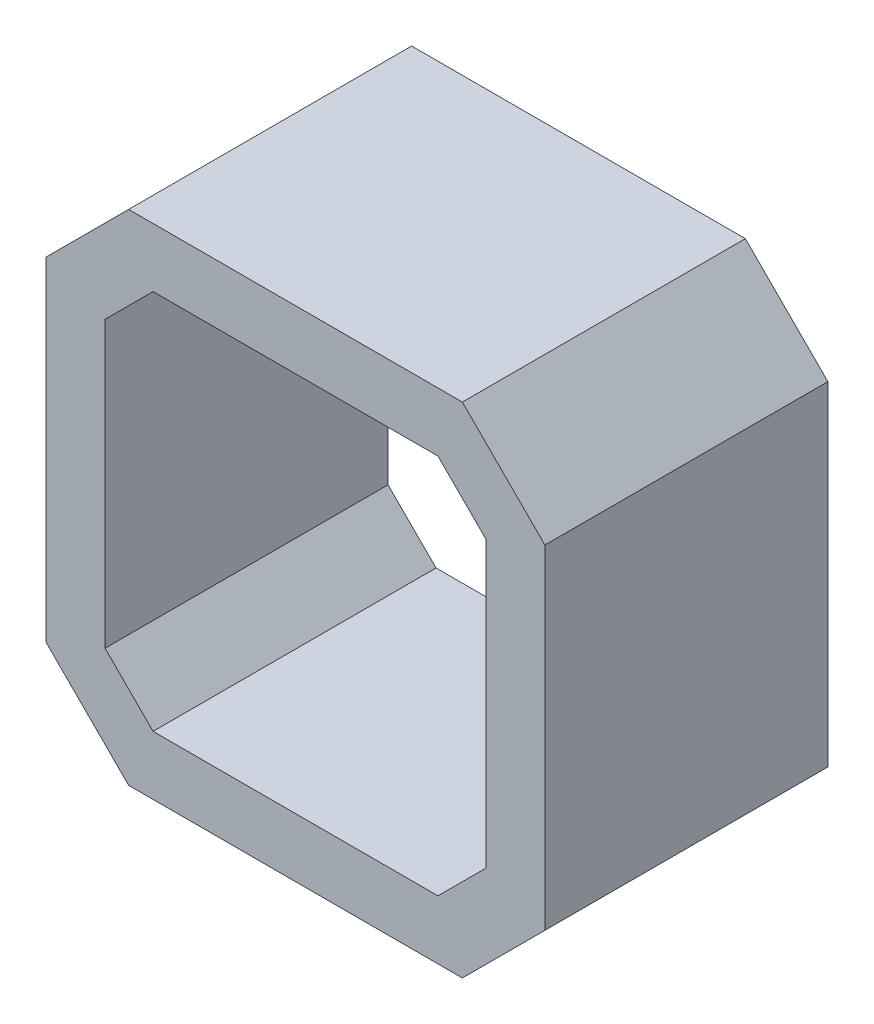
from build123d import *

# Parameters (mm, degrees)
BOSS_EXTRUDE1_DEPTH = 12


with BuildPart() as part:
    # Sketch1 → Boss-Extrude1 (new body, symmetric)
    with BuildSketch(Plane.XY):
        Polygon((-21.15, 14.15), (-14.15, 21.15), (14.15, 21.15), (21.15, 14.15), (21.15, -14.15), (14.15, -21.15), (-14.15, -21.15), (-21.15, -14.15), align=None)
        Polygon((-16.15, 12.078932188), (-12.078932188, 16.15), (12.078932188, 16.15), (16.15, 12.078932188), (16.15, -12.078932188), (12.078932188, -16.15), (-12.078932188, -16.15), (-16.15, -12.078932188), align=None, mode=Mode.SUBTRACT)
    extrude(amount=BOSS_EXTRUDE1_DEPTH, both=True)


solid = part.part
